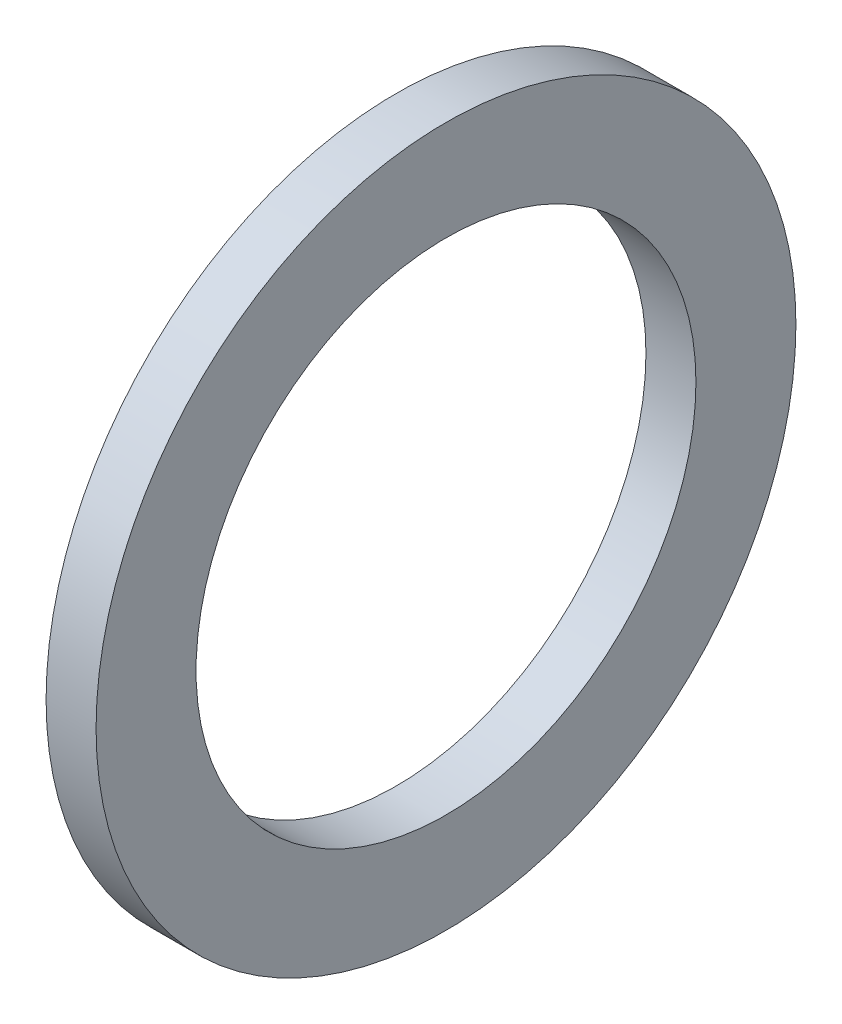
from build123d import *

# Parameters (mm, degrees)
SKETCH_1_R      = 3.5
SKETCH_1_R_2    = 2.5
EXTRUDE_1_DEPTH = 0.5


with BuildPart() as part:
    # 草图1 → 凸台-拉伸1 (new body)
    with BuildSketch(Plane(origin=(0, 0, 0), x_dir=(0, 0, -1), z_dir=(1, 0, 0))):
        Circle(SKETCH_1_R)
        Circle(SKETCH_1_R_2, mode=Mode.SUBTRACT)
    extrude(amount=EXTRUDE_1_DEPTH)


solid = part.part
